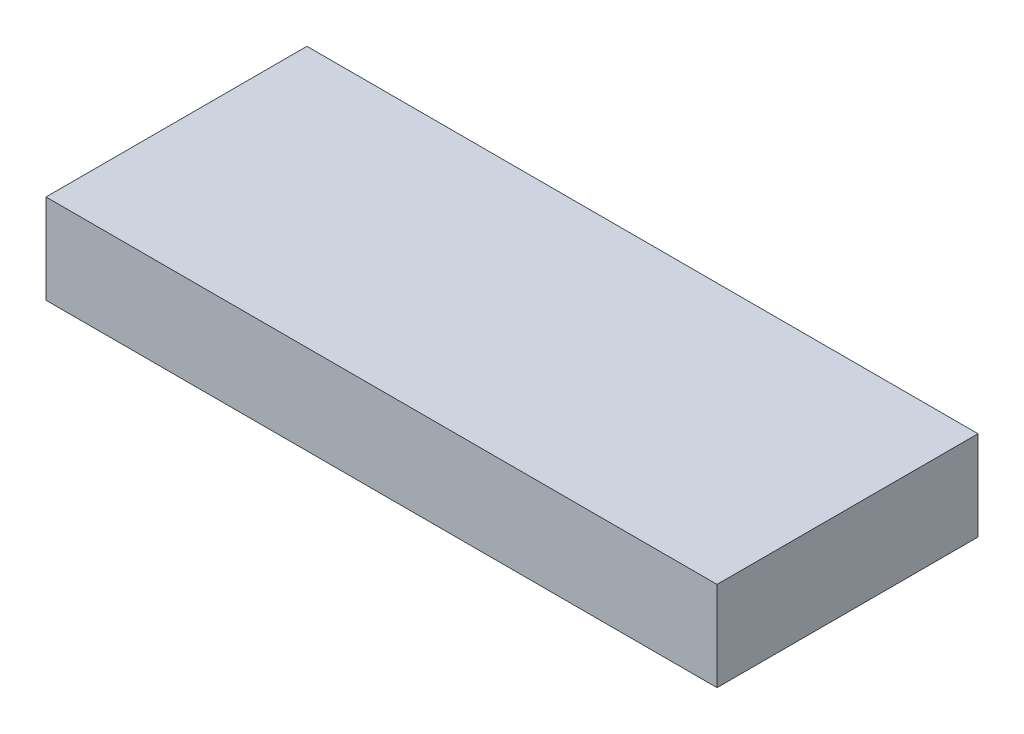
from build123d import *

# Parameters (mm, degrees)
SKETCH1_W                = 90
SKETCH1_H                = 35
COMMAND_STRIP_BASE_DEPTH = 12


with BuildPart() as part:
    # Sketch1 → Command Strip Base (new body)
    with BuildSketch(Plane(origin=(0, 0, 0), x_dir=(1, 0, 0), z_dir=(0, 1, 0))):
        with Locations((-89.452358061, 50.932029775)):
            Rectangle(SKETCH1_W, SKETCH1_H)
    extrude(amount=COMMAND_STRIP_BASE_DEPTH)


solid = part.part
